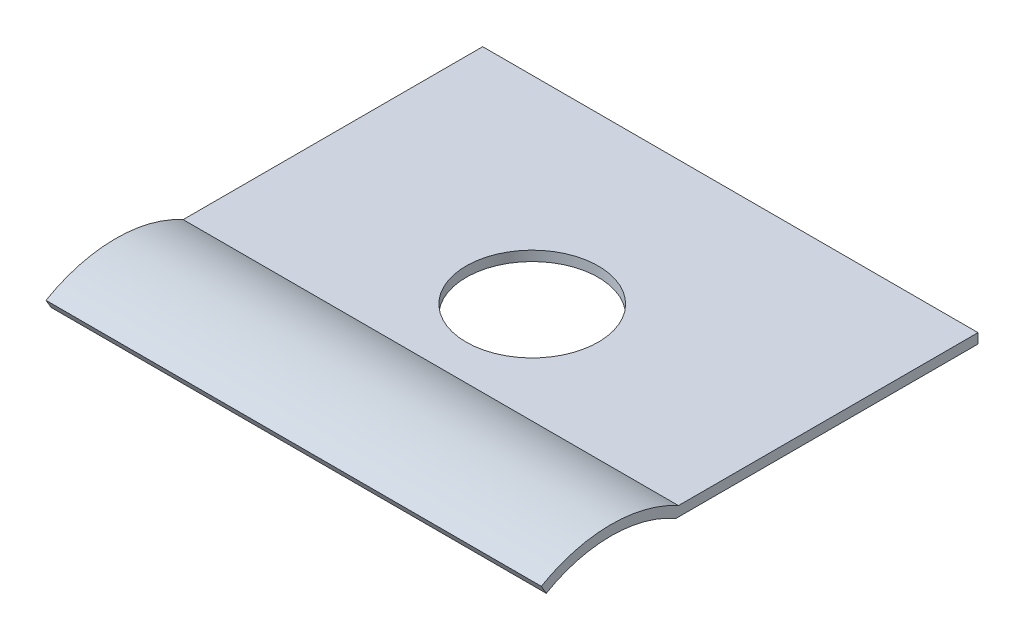
from build123d import *

# Parameters (mm, degrees)
BOSS_EXTRUDE1_DEPTH = 15
SKETCH4_R           = 2
CUT_EXTRUDE1_DEPTH  = 1.3


with BuildPart() as part:
    # Sketch3 → Boss-Extrude1 (new body)
    with BuildSketch(Plane(origin=(0, 0, 0), x_dir=(0, 0, -1), z_dir=(1, 0, 0))):
        with BuildLine():
            Line((3.925, 0), (13.075, 0))
            Line((13.075, 0), (13.075, 0.3))
            Line((13.075, 0.3), (4.003802629, 0.3))
            ThreePointArc((4.003802629, 0.3), (1.921620626, 0.825652519), (-0.15, 0.259807621))
            Line((-0.15, 0.259807621), (0, 0))
            ThreePointArc((0, 0), (1.9625, 0.52585029), (3.925, 0))
        make_face()
    extrude(amount=BOSS_EXTRUDE1_DEPTH)

    # Sketch4 → Cut-Extrude1 (cut, through all)
    with BuildSketch(Plane(origin=(0, 0.3, 0), x_dir=(1, 0, 0), z_dir=(0, 1, 0))):
        with Locations((7.5, 7.075)):
            Circle(SKETCH4_R)
    extrude(amount=-CUT_EXTRUDE1_DEPTH, mode=Mode.SUBTRACT)


solid = part.part
